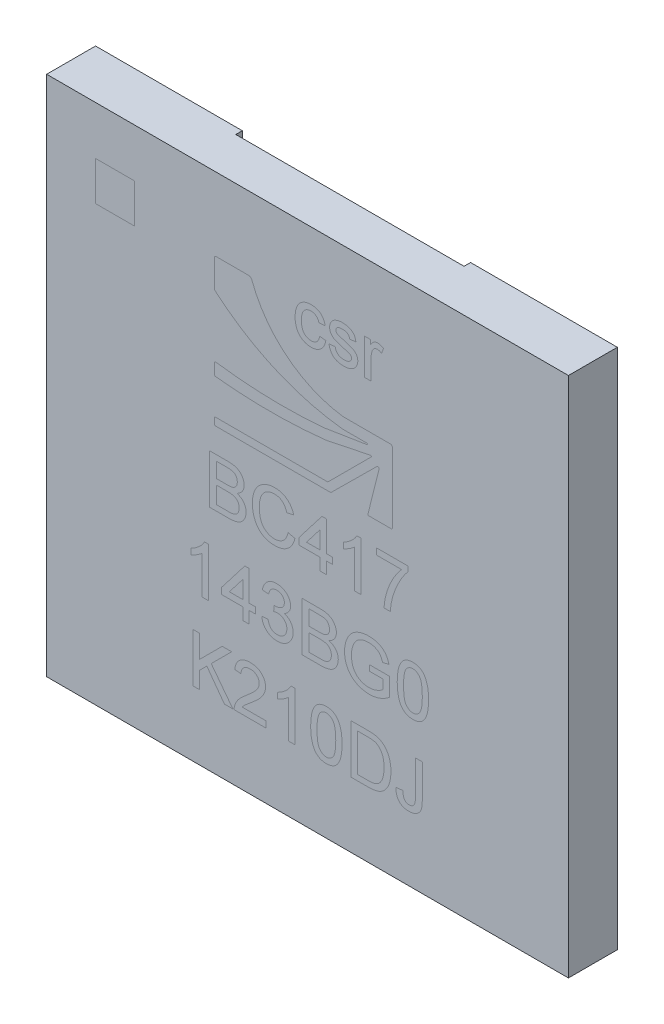
from build123d import *

# Parameters (mm, degrees)
SKETCH_1_W          = 8
SKETCH_1_H          = 8
EXTRUDE_1_DEPTH     = 0.75
SKETCH_2_R          = 0.154
EXTRUDE_2_DEPTH     = 0.1
SKETCH_3_W          = 3.5
SKETCH_3_H          = 6.43
CUT_EXTRUDE_2_DEPTH = 0.07
SKETCH_5_W          = 3.5
SKETCH_5_H          = 0.785
SKETCH_5_W_2        = 3.46960759
CUT_EXTRUDE_3_DEPTH = 0.1


with BuildPart() as part:
    # Эскиз1 → Бобышка-Вытянуть1 (new body)
    with BuildSketch(Plane.XY):
        Rectangle(SKETCH_1_W, SKETCH_1_H)
    extrude(amount=EXTRUDE_1_DEPTH)

    # Эскиз2 → Бобышка-Вытянуть2 (add)
    with BuildSketch(Plane(origin=(0, 0, 0), x_dir=(-1, 0, 0), z_dir=(0, 0, -1))):
        with Locations((3.598587951, 3.68)):
            Circle(SKETCH_2_R)
        with Locations((3.598587951, 3.11)):
            Circle(SKETCH_2_R)
        with Locations((3.598587951, 2.54)):
            Circle(SKETCH_2_R)
        with Locations((3.598587951, 1.97)):
            Circle(SKETCH_2_R)
        with Locations((3.598587951, 1.4)):
            Circle(SKETCH_2_R)
        with Locations((3.598587951, 0.83)):
            Circle(SKETCH_2_R)
        with Locations((3.598587951, 0.26)):
            Circle(SKETCH_2_R)
        with Locations((3.148587951, 3.11)):
            Circle(SKETCH_2_R)
        with Locations((3.148587951, 2.54)):
            Circle(SKETCH_2_R)
        with Locations((3.148587951, 1.97)):
            Circle(SKETCH_2_R)
        with Locations((3.148587951, 1.4)):
            Circle(SKETCH_2_R)
        with Locations((3.148587951, 0.83)):
            Circle(SKETCH_2_R)
        with Locations((3.148587951, 0.26)):
            Circle(SKETCH_2_R)
        with Locations((2.698587951, 3.11)):
            Circle(SKETCH_2_R)
        with Locations((2.698587951, 2.54)):
            Circle(SKETCH_2_R)
        with Locations((2.698587951, 1.97)):
            Circle(SKETCH_2_R)
        with Locations((2.698587951, 1.4)):
            Circle(SKETCH_2_R)
        with Locations((2.698587951, 0.83)):
            Circle(SKETCH_2_R)
        with Locations((2.698587951, 0.26)):
            Circle(SKETCH_2_R)
        with Locations((2.248587951, 3.11)):
            Circle(SKETCH_2_R)
        with Locations((2.248587951, 2.54)):
            Circle(SKETCH_2_R)
        with Locations((2.248587951, 1.97)):
            Circle(SKETCH_2_R)
        with Locations((2.248587951, 1.4)):
            Circle(SKETCH_2_R)
        with Locations((2.248587951, 0.83)):
            Circle(SKETCH_2_R)
        with Locations((2.248587951, 0.26)):
            Circle(SKETCH_2_R)
        with Locations((3.148587951, 3.68)):
            Circle(SKETCH_2_R)
        with Locations((2.698587951, 3.68)):
            Circle(SKETCH_2_R)
        with Locations((2.248587951, 3.68)):
            Circle(SKETCH_2_R)
        with Locations((2.248587951, -3.68)):
            Circle(SKETCH_2_R)
        with Locations((2.698587951, -3.68)):
            Circle(SKETCH_2_R)
        with Locations((3.148587951, -3.68)):
            Circle(SKETCH_2_R)
        with Locations((2.248587951, -0.26)):
            Circle(SKETCH_2_R)
        with Locations((2.248587951, -0.83)):
            Circle(SKETCH_2_R)
        with Locations((2.248587951, -1.4)):
            Circle(SKETCH_2_R)
        with Locations((2.248587951, -1.97)):
            Circle(SKETCH_2_R)
        with Locations((2.248587951, -2.54)):
            Circle(SKETCH_2_R)
        with Locations((2.248587951, -3.11)):
            Circle(SKETCH_2_R)
        with Locations((2.698587951, -0.26)):
            Circle(SKETCH_2_R)
        with Locations((2.698587951, -0.83)):
            Circle(SKETCH_2_R)
        with Locations((2.698587951, -1.4)):
            Circle(SKETCH_2_R)
        with Locations((2.698587951, -1.97)):
            Circle(SKETCH_2_R)
        with Locations((2.698587951, -2.54)):
            Circle(SKETCH_2_R)
        with Locations((2.698587951, -3.11)):
            Circle(SKETCH_2_R)
        with Locations((3.148587951, -0.26)):
            Circle(SKETCH_2_R)
        with Locations((3.148587951, -0.83)):
            Circle(SKETCH_2_R)
        with Locations((3.148587951, -1.4)):
            Circle(SKETCH_2_R)
        with Locations((3.148587951, -1.97)):
            Circle(SKETCH_2_R)
        with Locations((3.148587951, -2.54)):
            Circle(SKETCH_2_R)
        with Locations((3.148587951, -3.11)):
            Circle(SKETCH_2_R)
        with Locations((3.598587951, -0.26)):
            Circle(SKETCH_2_R)
        with Locations((3.598587951, -0.83)):
            Circle(SKETCH_2_R)
        with Locations((3.598587951, -1.4)):
            Circle(SKETCH_2_R)
        with Locations((3.598587951, -1.97)):
            Circle(SKETCH_2_R)
        with Locations((3.598587951, -2.54)):
            Circle(SKETCH_2_R)
        with Locations((3.598587951, -3.11)):
            Circle(SKETCH_2_R)
        with Locations((-3.598587951, -3.11)):
            Circle(SKETCH_2_R)
        with Locations((-3.598587951, -2.54)):
            Circle(SKETCH_2_R)
        with Locations((-3.598587951, -1.97)):
            Circle(SKETCH_2_R)
        with Locations((-3.598587951, -1.4)):
            Circle(SKETCH_2_R)
        with Locations((-3.598587951, -0.83)):
            Circle(SKETCH_2_R)
        with Locations((-3.598587951, -0.26)):
            Circle(SKETCH_2_R)
        with Locations((-3.148587951, -3.11)):
            Circle(SKETCH_2_R)
        with Locations((-3.148587951, -2.54)):
            Circle(SKETCH_2_R)
        with Locations((-3.148587951, -1.97)):
            Circle(SKETCH_2_R)
        with Locations((-3.148587951, -1.4)):
            Circle(SKETCH_2_R)
        with Locations((-3.148587951, -0.83)):
            Circle(SKETCH_2_R)
        with Locations((-3.148587951, -0.26)):
            Circle(SKETCH_2_R)
        with Locations((-2.698587951, -3.11)):
            Circle(SKETCH_2_R)
        with Locations((-2.698587951, -2.54)):
            Circle(SKETCH_2_R)
        with Locations((-2.698587951, -1.97)):
            Circle(SKETCH_2_R)
        with Locations((-2.698587951, -1.4)):
            Circle(SKETCH_2_R)
        with Locations((-2.698587951, -0.83)):
            Circle(SKETCH_2_R)
        with Locations((-2.698587951, -0.26)):
            Circle(SKETCH_2_R)
        with Locations((-2.248587951, -3.11)):
            Circle(SKETCH_2_R)
        with Locations((-2.248587951, -2.54)):
            Circle(SKETCH_2_R)
        with Locations((-2.248587951, -1.97)):
            Circle(SKETCH_2_R)
        with Locations((-2.248587951, -1.4)):
            Circle(SKETCH_2_R)
        with Locations((-2.248587951, -0.83)):
            Circle(SKETCH_2_R)
        with Locations((-2.248587951, -0.26)):
            Circle(SKETCH_2_R)
        with Locations((-3.148587951, -3.68)):
            Circle(SKETCH_2_R)
        with Locations((-2.698587951, -3.68)):
            Circle(SKETCH_2_R)
        with Locations((-2.248587951, -3.68)):
            Circle(SKETCH_2_R)
        with Locations((-2.248587951, 3.68)):
            Circle(SKETCH_2_R)
        with Locations((-2.698587951, 3.68)):
            Circle(SKETCH_2_R)
        with Locations((-3.148587951, 3.68)):
            Circle(SKETCH_2_R)
        with Locations((-2.248587951, 0.26)):
            Circle(SKETCH_2_R)
        with Locations((-2.248587951, 0.83)):
            Circle(SKETCH_2_R)
        with Locations((-2.248587951, 1.4)):
            Circle(SKETCH_2_R)
        with Locations((-2.248587951, 1.97)):
            Circle(SKETCH_2_R)
        with Locations((-2.248587951, 2.54)):
            Circle(SKETCH_2_R)
        with Locations((-2.248587951, 3.11)):
            Circle(SKETCH_2_R)
        with Locations((-2.698587951, 0.26)):
            Circle(SKETCH_2_R)
        with Locations((-2.698587951, 0.83)):
            Circle(SKETCH_2_R)
        with Locations((-2.698587951, 1.4)):
            Circle(SKETCH_2_R)
        with Locations((-2.698587951, 1.97)):
            Circle(SKETCH_2_R)
        with Locations((-2.698587951, 2.54)):
            Circle(SKETCH_2_R)
        with Locations((-2.698587951, 3.11)):
            Circle(SKETCH_2_R)
        with Locations((-3.148587951, 0.26)):
            Circle(SKETCH_2_R)
        with Locations((-3.148587951, 0.83)):
            Circle(SKETCH_2_R)
        with Locations((-3.148587951, 1.4)):
            Circle(SKETCH_2_R)
        with Locations((-3.148587951, 1.97)):
            Circle(SKETCH_2_R)
        with Locations((-3.148587951, 2.54)):
            Circle(SKETCH_2_R)
        with Locations((-3.148587951, 3.11)):
            Circle(SKETCH_2_R)
        with Locations((-3.598587951, 0.26)):
            Circle(SKETCH_2_R)
        with Locations((-3.598587951, 0.83)):
            Circle(SKETCH_2_R)
        with Locations((-3.598587951, 1.4)):
            Circle(SKETCH_2_R)
        with Locations((-3.598587951, 1.97)):
            Circle(SKETCH_2_R)
        with Locations((-3.598587951, 2.54)):
            Circle(SKETCH_2_R)
        with Locations((-3.598587951, 3.11)):
            Circle(SKETCH_2_R)
        with Locations((-3.598587951, 3.68)):
            Circle(SKETCH_2_R)
        with Locations((-3.598587951, -3.705)):
            Circle(SKETCH_2_R)
    extrude(amount=EXTRUDE_2_DEPTH)

    # Эскиз3 → Вырез-Вытянуть2 (cut)
    with BuildSketch(Plane(origin=(0, 0, 0), x_dir=(-1, 0, 0), z_dir=(0, 0, -1))):
        Rectangle(SKETCH_3_W, SKETCH_3_H)
    extrude(amount=-CUT_EXTRUDE_2_DEPTH, mode=Mode.SUBTRACT)

    # Эскиз5 → Вырез-Вытянуть3 (cut)
    with BuildSketch(Plane(origin=(0, 0, 0), x_dir=(-1, 0, 0), z_dir=(0, 0, -1))):
        with Locations((0, 3.6075)):
            Rectangle(SKETCH_5_W, SKETCH_5_H)
        with Locations((-0.015196205, -3.6075)):
            Rectangle(SKETCH_5_W_2, SKETCH_5_H)
    extrude(amount=-CUT_EXTRUDE_3_DEPTH, mode=Mode.SUBTRACT)


solid = part.part
